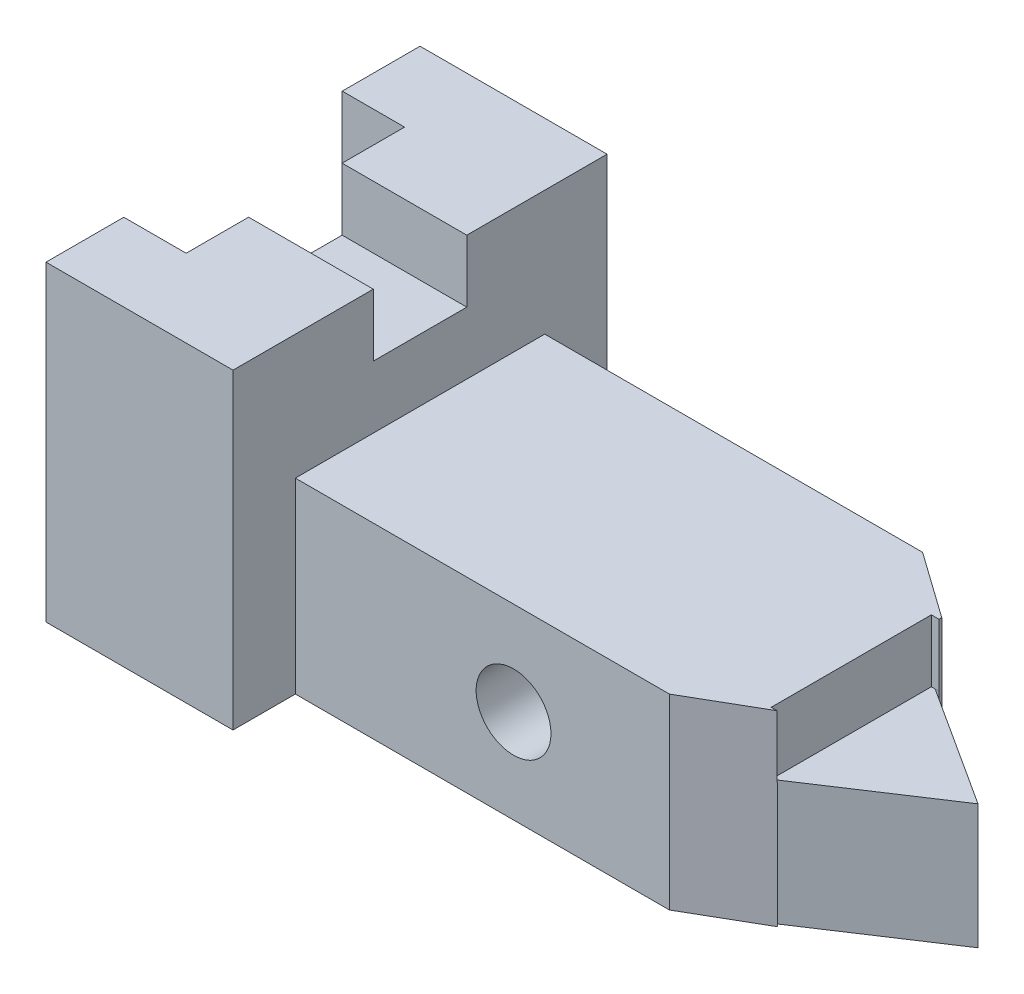
from build123d import *

# Parameters (mm, degrees)
SKETCH1_W           = 30
SKETCH1_H           = 50
BOSS_EXTRUDE1_DEPTH = 60
SKETCH2_W           = 40
SKETCH2_H           = 30
BOSS_EXTRUDE2_DEPTH = 90
SKETCH3_R           = 6
CUT_EXTRUDE1_DEPTH  = 90
CUT_EXTRUDE3_DEPTH  = 90
SKETCH6_W           = 25.687042716
SKETCH6_H           = 10
CUT_EXTRUDE4_DEPTH  = 20
SKETCH7_W           = 18.776678674
SKETCH7_H           = 30
CUT_EXTRUDE5_DEPTH  = 6
SKETCH8_W           = 18.776678674
SKETCH8_H           = 30
CUT_EXTRUDE6_DEPTH  = 1
SKETCH9_W           = 18.776678674
SKETCH9_H           = 30
CUT_EXTRUDE7_DEPTH  = 8
CUT_EXTRUDE8_DEPTH  = 48
SKETCH11_W          = 20
SKETCH11_H          = 15
CUT_EXTRUDE9_DEPTH  = 10
SKETCH12_W          = 10
SKETCH12_H          = 35.03931538
CUT_EXTRUDE10_DEPTH = 70


with BuildPart() as part:
    # Sketch1 → Boss-Extrude1 (new body)
    with BuildSketch(Plane.XY):
        with Locations((-6.834061135, 8.187772926)):
            Rectangle(SKETCH1_W, SKETCH1_H)
    extrude(amount=-BOSS_EXTRUDE1_DEPTH)

    # Sketch2 → Boss-Extrude2 (add)
    with BuildSketch(Plane(origin=(8.165938865, 0, 0), x_dir=(0, 0, -1), z_dir=(1, 0, 0))):
        with Locations((30, -1.812227074)):
            Rectangle(SKETCH2_W, SKETCH2_H)
    extrude(amount=BOSS_EXTRUDE2_DEPTH)

    # Sketch3 → Cut-Extrude1 (cut)
    with BuildSketch(Plane.XY.offset(-10)):
        with Locations((43.165938865, -1.812227074)):
            Circle(SKETCH3_R)
    extrude(amount=-CUT_EXTRUDE1_DEPTH, mode=Mode.SUBTRACT)

    # Sketch4 → Cut-Extrude3 (cut)
    with BuildSketch(Plane(origin=(0, 13.187772926, 0), x_dir=(1, 0, 0), z_dir=(0, 1, 0))):
        Polygon((79.389260191, 50), (68.777599528, 50), (79.389260191, 42.463070185), align=None)
        Polygon((79.389260191, 16.479787589), (68.165938865, 10), (79.389260191, 10), align=None)
    extrude(amount=-CUT_EXTRUDE3_DEPTH, mode=Mode.SUBTRACT)

    # Sketch6 → Cut-Extrude4 (cut)
    with BuildSketch(Plane(origin=(98.165938865, 0, 0), x_dir=(0, 0, -1), z_dir=(1, 0, 0))):
        with Locations((29.167914445, 8.187772926)):
            Rectangle(SKETCH6_W, SKETCH6_H)
    extrude(amount=-CUT_EXTRUDE4_DEPTH, mode=Mode.SUBTRACT)

    # Sketch7 → Cut-Extrude5 (cut)
    with BuildSketch(Plane.XY.offset(-10)):
        with Locations((88.777599528, -1.812227074)):
            Rectangle(SKETCH7_W, SKETCH7_H)
    extrude(amount=-CUT_EXTRUDE5_DEPTH, mode=Mode.SUBTRACT)

    # Sketch8 → Cut-Extrude6 (cut)
    with BuildSketch(Plane.XY.offset(-16)):
        with Locations((88.777599528, -1.812227074)):
            Rectangle(SKETCH8_W, SKETCH8_H)
    extrude(amount=-CUT_EXTRUDE6_DEPTH, mode=Mode.SUBTRACT)

    # Sketch9 → Cut-Extrude7 (cut)
    with BuildSketch(Plane(origin=(0, 0, -50), x_dir=(-1, 0, 0), z_dir=(0, 0, -1))):
        with Locations((-88.777599528, -1.812227074)):
            Rectangle(SKETCH9_W, SKETCH9_H)
    extrude(amount=-CUT_EXTRUDE7_DEPTH, mode=Mode.SUBTRACT)

    # Sketch10 → Cut-Extrude8 (cut)
    with BuildSketch(Plane(origin=(0, 3.187772926, 0), x_dir=(1, 0, 0), z_dir=(0, 1, 0))):
        Polygon((98.165938865, 17), (98.165938865, 29.5), (78.165938865, 16.324393087), (79.179406262, 16.358628366), (79.389260191, 16.479787589), (79.389260191, 17), align=None)
        Polygon((79.389260191, 42.011075028), (78.777599528, 42.011435803), (98.165938865, 29.5), (98.165938865, 42), (79.389260191, 42), align=None)
    extrude(amount=-CUT_EXTRUDE8_DEPTH, mode=Mode.SUBTRACT)

    # Sketch11 → Cut-Extrude9 (cut)
    with BuildSketch(Plane(origin=(0, 33.187772926, 0), x_dir=(1, 0, 0), z_dir=(0, 1, 0))):
        with Locations((-1.834061135, 30)):
            Rectangle(SKETCH11_W, SKETCH11_H)
    extrude(amount=-CUT_EXTRUDE9_DEPTH, mode=Mode.SUBTRACT)

    # Sketch12 → Cut-Extrude10 (cut)
    with BuildSketch(Plane(origin=(0, 33.187772926, 0), x_dir=(1, 0, 0), z_dir=(0, 1, 0))):
        with Locations((-16.834061135, 30)):
            Rectangle(SKETCH12_W, SKETCH12_H)
    extrude(amount=-CUT_EXTRUDE10_DEPTH, mode=Mode.SUBTRACT)


solid = part.part
